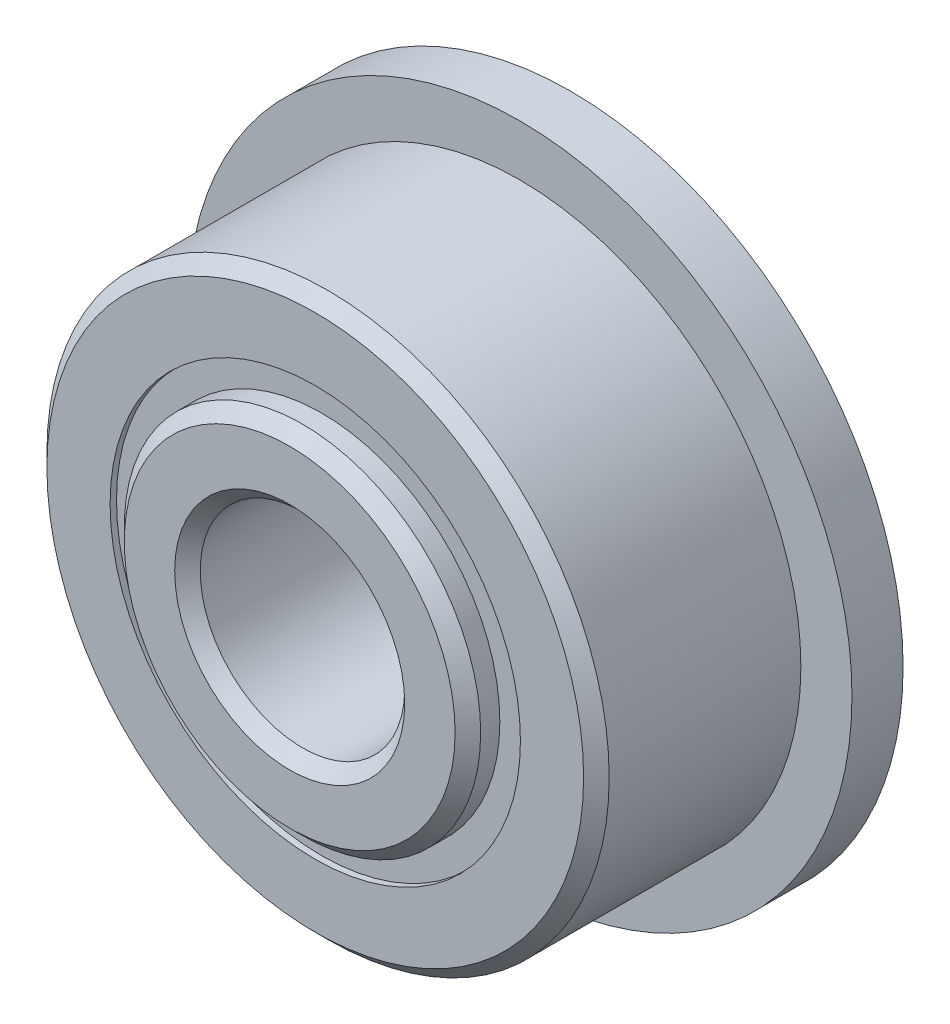
from build123d import *

# Parameters (mm, degrees)
CIRPATTERN1_COUNT = 10
SKETCH5_W         = 1.957414803
SKETCH5_H         = 0.837362638
SKETCH6_W         = 1.5875
SKETCH6_H         = 3.946943681


with BuildPart() as part:
    # Sketch1 → Revolve1 (revolve)
    with BuildSketch(Plane(origin=(0, 0, 0), x_dir=(0, 0, -1), z_dir=(1, 0, 0))):
        with BuildLine():
            Line((3.571875, 8.73125), (-3.571875, 8.73125))
            Line((-3.571875, 8.73125), (-3.96875, 8.334375))
            Line((-3.96875, 8.334375), (-3.96875, 6.371806319))
            Line((-3.96875, 6.371806319), (-1.763888889, 6.371806319))
            ThreePointArc((-1.763888889, 6.371806319), (0, 7.766022697), (1.763888889, 6.371806319))
            Line((1.763888889, 6.371806319), (3.96875, 6.371806319))
            Line((3.96875, 6.371806319), (3.96875, 8.334375))
            Line((3.96875, 8.334375), (3.571875, 8.73125))
        make_face()
    revolve(axis=Axis((0, 0, 3.96875), (0, 0, -1)))

    # Sketch6 → Revolve6 (revolve)
    with BuildSketch(Plane(origin=(0, 0, 0), x_dir=(0, 0, -1), z_dir=(1, 0, 0))):
        with Locations((3.175, 8.34527816)):
            Rectangle(SKETCH6_W, SKETCH6_H)
    revolve(axis=Axis((0, 0, -3.96875), (0, 0, 1)))


with BuildPart() as body_2:
    # Sketch3 → Revolve3 (revolve)
    with BuildSketch(Plane(origin=(0, 0, 0), x_dir=(0, 0, -1), z_dir=(1, 0, 0))):
        with BuildLine():
            Line((-4.7625, 3.571875), (-4.7625, 5.137568681))
            Line((-4.7625, 5.137568681), (-4.365625, 5.534443681))
            Line((-4.365625, 5.534443681), (-1.763888889, 5.534443681))
            ThreePointArc((-1.763888889, 5.534443681), (0, 4.140227303), (1.763888889, 5.534443681))
            Line((1.763888889, 5.534443681), (4.365625, 5.534443681))
            Line((4.365625, 5.534443681), (4.7625, 5.137568681))
            Line((4.7625, 5.137568681), (4.7625, 3.571875))
            Line((4.7625, 3.571875), (4.365625, 3.175))
            Line((4.365625, 3.175), (-4.365625, 3.175))
            Line((-4.365625, 3.175), (-4.7625, 3.571875))
        make_face()
    revolve(axis=Axis((0, 0, 3.96875), (0, 0, -1)))


with BuildPart() as body_3:
    # Sketch4 → Revolve4 (revolve)
    with BuildSketch(Plane(origin=(0, 0, 0), x_dir=(0, 0, -1), z_dir=(1, 0, 0))):
        with BuildLine():
            Line((-1.812897697, 5.953125), (1.812897697, 5.953125))
            ThreePointArc((1.812897697, 5.953125), (0, 7.766022697), (-1.812897697, 5.953125))
        make_face()
    revolve(axis=Axis((0, 5.953125, 1.812897697), (0, 0, -1)))


with BuildPart() as cirpattern1_1:
    # CirPattern1: pattern copy
    add(body_3.part.rotate(Axis((0, 0, -3.96875), (0, 0, 1)), 1 * 360 / CIRPATTERN1_COUNT))


with BuildPart() as cirpattern1_2:
    # CirPattern1: pattern copy
    add(body_3.part.rotate(Axis((0, 0, -3.96875), (0, 0, 1)), 2 * 360 / CIRPATTERN1_COUNT))


with BuildPart() as cirpattern1_3:
    # CirPattern1: pattern copy
    add(body_3.part.rotate(Axis((0, 0, -3.96875), (0, 0, 1)), 3 * 360 / CIRPATTERN1_COUNT))


with BuildPart() as cirpattern1_4:
    # CirPattern1: pattern copy
    add(body_3.part.rotate(Axis((0, 0, -3.96875), (0, 0, 1)), 4 * 360 / CIRPATTERN1_COUNT))


with BuildPart() as cirpattern1_5:
    # CirPattern1: pattern copy
    add(body_3.part.rotate(Axis((0, 0, -3.96875), (0, 0, 1)), 5 * 360 / CIRPATTERN1_COUNT))


with BuildPart() as cirpattern1_6:
    # CirPattern1: pattern copy
    add(body_3.part.rotate(Axis((0, 0, -3.96875), (0, 0, 1)), 6 * 360 / CIRPATTERN1_COUNT))


with BuildPart() as cirpattern1_7:
    # CirPattern1: pattern copy
    add(body_3.part.rotate(Axis((0, 0, -3.96875), (0, 0, 1)), 7 * 360 / CIRPATTERN1_COUNT))


with BuildPart() as cirpattern1_8:
    # CirPattern1: pattern copy
    add(body_3.part.rotate(Axis((0, 0, -3.96875), (0, 0, 1)), 8 * 360 / CIRPATTERN1_COUNT))


with BuildPart() as cirpattern1_9:
    # CirPattern1: pattern copy
    add(body_3.part.rotate(Axis((0, 0, -3.96875), (0, 0, 1)), 9 * 360 / CIRPATTERN1_COUNT))


with BuildPart() as body_13:
    # Sketch5 → Revolve5 (revolve)
    with BuildSketch(Plane(origin=(0, 0, 0), x_dir=(0, 0, -1), z_dir=(1, 0, 0))):
        with Locations((-2.791605099, 5.953125)):
            Rectangle(SKETCH5_W, SKETCH5_H)
        with Locations((2.791605099, 5.953125)):
            Rectangle(SKETCH5_W, SKETCH5_H)
    revolve(axis=Axis((0, 0, 3.96875), (0, 0, -1)))


solid = Compound([part.part, body_2.part, body_3.part, cirpattern1_1.part, cirpattern1_2.part, cirpattern1_3.part, cirpattern1_4.part, cirpattern1_5.part, cirpattern1_6.part, cirpattern1_7.part, cirpattern1_8.part, cirpattern1_9.part, body_13.part])
